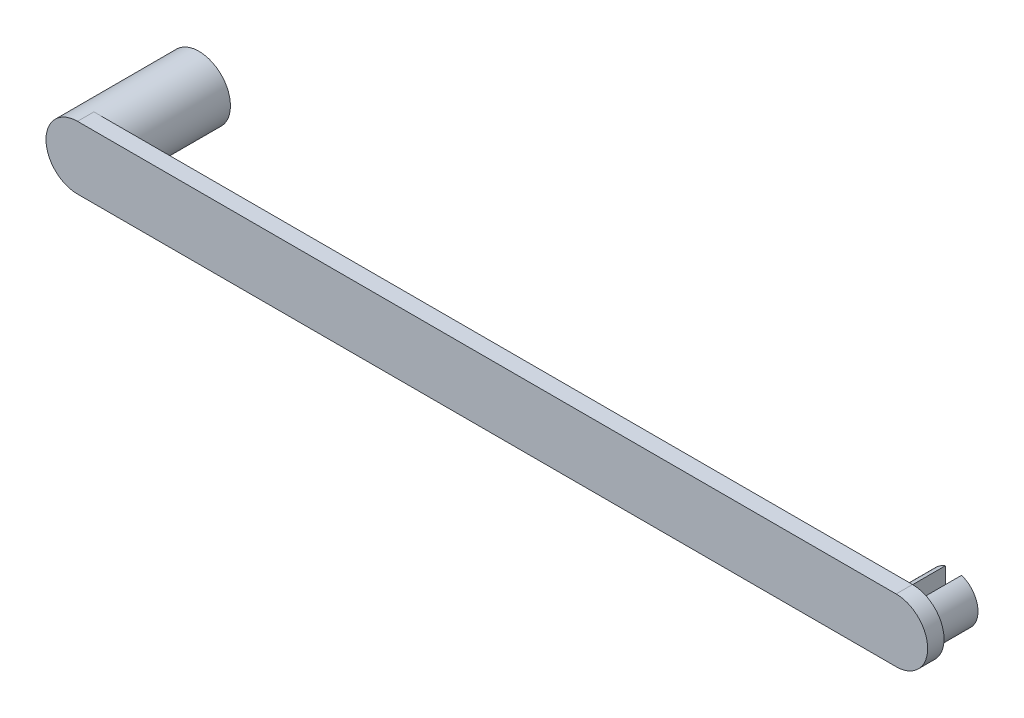
from build123d import *

# Parameters (mm, degrees)
SKETCH1_R           = 3.85
BOSS_EXTRUDE1_DEPTH = 12.83
SKETCH2_R           = 3.85
BOSS_EXTRUDE3_DEPTH = 2
BOSS_EXTRUDE5_DEPTH = 5


with BuildPart() as part:
    # Sketch1 → Boss-Extrude1 (new body)
    with BuildSketch(Plane.XY):
        with Locations(Location((0, 0, 0), (0, 0, 180))):
            Circle(SKETCH1_R)
    extrude(amount=BOSS_EXTRUDE1_DEPTH)

    # Sketch2 → Boss-Extrude3 (add)
    with BuildSketch(Plane.XY.offset(12.83)):
        with Locations((100, 0)):
            Circle(SKETCH2_R)
        with BuildLine():
            Line((100, 3.85), (0, 3.85))
            ThreePointArc((0, 3.85), (2.722361108, 2.722361108), (3.85, 0))
            ThreePointArc((3.85, 0), (2.722361108, -2.722361108), (0, -3.85))
            Line((0, -3.85), (100, -3.85))
            ThreePointArc((100, -3.85), (96.15, 0), (100, 3.85))
        make_face()
        with BuildLine():
            ThreePointArc((3.85, 0), (2.722361108, 2.722361108), (0, 3.85))
            Line((0, 3.85), (0, -3.85))
            ThreePointArc((0, -3.85), (2.722361108, -2.722361108), (3.85, 0))
        make_face()
        with BuildLine():
            Line((0, -3.85), (0, 3.85))
            ThreePointArc((0, 3.85), (-3.85, 0), (0, -3.85))
        make_face()
    extrude(amount=BOSS_EXTRUDE3_DEPTH)

    # Sketch3 → Boss-Extrude5 (add)
    with BuildSketch(Plane(origin=(0, 0, 12.83), x_dir=(-1, 0, 0), z_dir=(0, 0, -1))):
        with BuildLine():
            Line((-101, -2.828427125), (-101, 2.828427125))
            ThreePointArc((-101, 2.828427125), (-103, 0), (-101, -2.828427125))
        make_face()
        with BuildLine():
            ThreePointArc((-97, 0), (-97.550510257, 1.732050808), (-99, 2.828427125))
            Line((-99, 2.828427125), (-99, -2.828427125))
            ThreePointArc((-99, -2.828427125), (-97.550510257, -1.732050808), (-97, 0))
        make_face()
    extrude(amount=BOSS_EXTRUDE5_DEPTH)


solid = part.part
